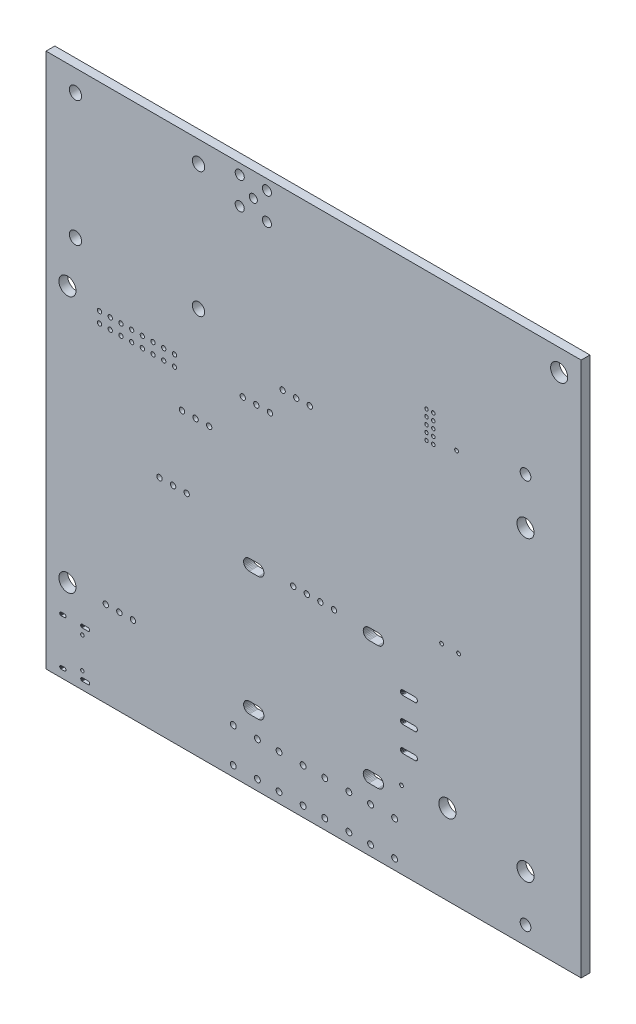
from build123d import *

# Parameters (mm, degrees)
SKICA1_W                = 100
SKICA1_H                = 100
SKICA1_R                = 1.15
SKICA1_R_2              = 0.85
SKICA1_R_3              = 0.75
SKICA1_R_4              = 1.6
SKICA1_R_5              = 0.4
SKICA1_R_6              = 0.5
SKICA1_R_7              = 0.325
SKICA1_R_8              = 1
SKICA1_R_9              = 0.35
SKICA1_R_10             = 0.55
P_IDAT_VYSUNUT_M1_DEPTH = 1.64716


with BuildPart() as part:
    # Skica1 → Přidat vysunutím1 (new body)
    with BuildSketch(Plane.XY.offset(1.64716)):
        with Locations((50, -50)):
            Rectangle(SKICA1_W, SKICA1_H)
        with Locations((5.5, -4)):
            Circle(SKICA1_R, mode=Mode.SUBTRACT)
        with Locations((28.5, -4)):
            Circle(SKICA1_R, mode=Mode.SUBTRACT)
        with Locations((36.195, -1.92)):
            Circle(SKICA1_R_2, mode=Mode.SUBTRACT)
        with Locations((36.195, -7)):
            Circle(SKICA1_R_2, mode=Mode.SUBTRACT)
        with Locations((41.275, -1.92)):
            Circle(SKICA1_R_2, mode=Mode.SUBTRACT)
        with Locations((38.735, -4.46)):
            Circle(SKICA1_R_3, mode=Mode.SUBTRACT)
        with Locations((41.275, -7)):
            Circle(SKICA1_R_2, mode=Mode.SUBTRACT)
        with Locations((5.5, -27.46)):
            Circle(SKICA1_R, mode=Mode.SUBTRACT)
        with Locations((4, -36)):
            Circle(SKICA1_R_4, mode=Mode.SUBTRACT)
        with Locations((10, -37.08)):
            Circle(SKICA1_R_5, mode=Mode.SUBTRACT)
        with Locations((12, -37.08)):
            Circle(SKICA1_R_5, mode=Mode.SUBTRACT)
        with Locations((14, -37.08)):
            Circle(SKICA1_R_5, mode=Mode.SUBTRACT)
        with Locations((16, -37.08)):
            Circle(SKICA1_R_5, mode=Mode.SUBTRACT)
        with Locations((18, -37.08)):
            Circle(SKICA1_R_5, mode=Mode.SUBTRACT)
        with Locations((20, -37.08)):
            Circle(SKICA1_R_5, mode=Mode.SUBTRACT)
        with Locations((22, -37.08)):
            Circle(SKICA1_R_5, mode=Mode.SUBTRACT)
        with Locations((24, -37.08)):
            Circle(SKICA1_R_5, mode=Mode.SUBTRACT)
        with Locations((10, -39.08)):
            Circle(SKICA1_R_5, mode=Mode.SUBTRACT)
        with Locations((12, -39.08)):
            Circle(SKICA1_R_5, mode=Mode.SUBTRACT)
        with Locations((14, -39.08)):
            Circle(SKICA1_R_5, mode=Mode.SUBTRACT)
        with Locations((16, -39.08)):
            Circle(SKICA1_R_5, mode=Mode.SUBTRACT)
        with Locations((18, -39.08)):
            Circle(SKICA1_R_5, mode=Mode.SUBTRACT)
        with Locations((20, -39.08)):
            Circle(SKICA1_R_5, mode=Mode.SUBTRACT)
        with Locations((22, -39.08)):
            Circle(SKICA1_R_5, mode=Mode.SUBTRACT)
        with Locations((24, -39.08)):
            Circle(SKICA1_R_5, mode=Mode.SUBTRACT)
        with Locations((25.415, -45.466)):
            Circle(SKICA1_R_6, mode=Mode.SUBTRACT)
        with Locations((28.5, -27.46)):
            Circle(SKICA1_R, mode=Mode.SUBTRACT)
        with Locations((36.766, -37.592)):
            Circle(SKICA1_R_6, mode=Mode.SUBTRACT)
        with Locations((39.306, -37.592)):
            Circle(SKICA1_R_6, mode=Mode.SUBTRACT)
        with Locations((41.846, -37.592)):
            Circle(SKICA1_R_6, mode=Mode.SUBTRACT)
        with Locations((44.211, -32.766)):
            Circle(SKICA1_R_6, mode=Mode.SUBTRACT)
        with Locations((46.751, -32.766)):
            Circle(SKICA1_R_6, mode=Mode.SUBTRACT)
        with Locations((49.291, -32.766)):
            Circle(SKICA1_R_6, mode=Mode.SUBTRACT)
        with Locations((27.955, -45.466)):
            Circle(SKICA1_R_6, mode=Mode.SUBTRACT)
        with Locations((30.495, -45.466)):
            Circle(SKICA1_R_6, mode=Mode.SUBTRACT)
        with Locations((71.1, -22.37)):
            Circle(SKICA1_R_7, mode=Mode.SUBTRACT)
        with Locations((72.37, -22.37)):
            Circle(SKICA1_R_7, mode=Mode.SUBTRACT)
        with Locations((71.1, -23.64)):
            Circle(SKICA1_R_7, mode=Mode.SUBTRACT)
        with Locations((72.37, -23.64)):
            Circle(SKICA1_R_7, mode=Mode.SUBTRACT)
        with Locations((71.1, -24.91)):
            Circle(SKICA1_R_7, mode=Mode.SUBTRACT)
        with Locations((72.37, -24.91)):
            Circle(SKICA1_R_7, mode=Mode.SUBTRACT)
        with Locations((95.885, -4.064)):
            Circle(SKICA1_R_4, mode=Mode.SUBTRACT)
        with Locations((89.6, -23.7)):
            Circle(SKICA1_R_8, mode=Mode.SUBTRACT)
        with Locations((71.1, -26.18)):
            Circle(SKICA1_R_7, mode=Mode.SUBTRACT)
        with Locations((72.37, -26.18)):
            Circle(SKICA1_R_7, mode=Mode.SUBTRACT)
        with Locations((71.1, -27.45)):
            Circle(SKICA1_R_7, mode=Mode.SUBTRACT)
        with Locations((72.37, -27.45)):
            Circle(SKICA1_R_7, mode=Mode.SUBTRACT)
        with Locations((76.708, -26.289)):
            Circle(SKICA1_R_9, mode=Mode.SUBTRACT)
        with Locations((89.6, -32.345)):
            Circle(SKICA1_R_4, mode=Mode.SUBTRACT)
        with Locations((21.209, -58.42)):
            Circle(SKICA1_R_6, mode=Mode.SUBTRACT)
        with Locations((23.749, -58.42)):
            Circle(SKICA1_R_6, mode=Mode.SUBTRACT)
        with Locations((26.289, -58.42)):
            Circle(SKICA1_R_6, mode=Mode.SUBTRACT)
        with Locations((46.19, -63.5)):
            Circle(SKICA1_R_6, mode=Mode.SUBTRACT)
        with Locations((48.73, -63.5)):
            Circle(SKICA1_R_6, mode=Mode.SUBTRACT)
        with Locations((4, -84)):
            Circle(SKICA1_R_4, mode=Mode.SUBTRACT)
        with Locations((11.161, -83.947)):
            Circle(SKICA1_R_6, mode=Mode.SUBTRACT)
        with Locations((13.701, -83.947)):
            Circle(SKICA1_R_6, mode=Mode.SUBTRACT)
        with Locations((16.241, -83.947)):
            Circle(SKICA1_R_6, mode=Mode.SUBTRACT)
        with Locations((6.791, -91.09)):
            Circle(SKICA1_R_7, mode=Mode.SUBTRACT)
        with Locations((6.791, -96.87)):
            Circle(SKICA1_R_7, mode=Mode.SUBTRACT)
        with Locations((34.992, -91.58)):
            Circle(SKICA1_R_10, mode=Mode.SUBTRACT)
        with Locations((34.992, -98.08)):
            Circle(SKICA1_R_10, mode=Mode.SUBTRACT)
        with Locations((39.492, -91.58)):
            Circle(SKICA1_R_10, mode=Mode.SUBTRACT)
        with Locations((43.542, -91.58)):
            Circle(SKICA1_R_10, mode=Mode.SUBTRACT)
        with Locations((48.042, -91.58)):
            Circle(SKICA1_R_10, mode=Mode.SUBTRACT)
        with Locations((39.492, -98.08)):
            Circle(SKICA1_R_10, mode=Mode.SUBTRACT)
        with Locations((43.542, -98.08)):
            Circle(SKICA1_R_10, mode=Mode.SUBTRACT)
        with Locations((48.042, -98.08)):
            Circle(SKICA1_R_10, mode=Mode.SUBTRACT)
        with Locations((51.27, -63.5)):
            Circle(SKICA1_R_6, mode=Mode.SUBTRACT)
        with Locations((53.81, -63.5)):
            Circle(SKICA1_R_6, mode=Mode.SUBTRACT)
        with Locations((73.914, -58.928)):
            Circle(SKICA1_R_9, mode=Mode.SUBTRACT)
        with Locations((77.089, -58.928)):
            Circle(SKICA1_R_9, mode=Mode.SUBTRACT)
        with Locations((66.421, -85.598)):
            Circle(SKICA1_R_9, mode=Mode.SUBTRACT)
        with Locations((52.092, -91.58)):
            Circle(SKICA1_R_10, mode=Mode.SUBTRACT)
        with Locations((56.592, -91.58)):
            Circle(SKICA1_R_10, mode=Mode.SUBTRACT)
        with Locations((60.642, -91.58)):
            Circle(SKICA1_R_10, mode=Mode.SUBTRACT)
        with Locations((52.092, -98.08)):
            Circle(SKICA1_R_10, mode=Mode.SUBTRACT)
        with Locations((56.592, -98.08)):
            Circle(SKICA1_R_10, mode=Mode.SUBTRACT)
        with Locations((60.642, -98.08)):
            Circle(SKICA1_R_10, mode=Mode.SUBTRACT)
        with Locations((65.142, -91.58)):
            Circle(SKICA1_R_10, mode=Mode.SUBTRACT)
        with Locations((65.142, -98.08)):
            Circle(SKICA1_R_10, mode=Mode.SUBTRACT)
        with Locations((75, -85)):
            Circle(SKICA1_R_4, mode=Mode.SUBTRACT)
        with Locations((89.6, -87.955)):
            Circle(SKICA1_R_4, mode=Mode.SUBTRACT)
        with Locations((89.6, -96.6)):
            Circle(SKICA1_R_8, mode=Mode.SUBTRACT)
        Polygon((40.257349, -63.261957), (40.416462, -63.392538), (40.547043, -63.551651), (40.644074, -63.733182), (40.703825, -63.930155), (40.724, -64.135), (40.703825, -64.339845), (40.644074, -64.536818), (40.547043, -64.718349), (40.416462, -64.877462), (40.257349, -65.008043), (40.075818, -65.105074), (39.878845, -65.164825), (39.674, -65.185), (37.974, -65.185), (37.769155, -65.164825), (37.572182, -65.105074), (37.390651, -65.008043), (37.231538, -64.877462), (37.100957, -64.718349), (37.003926, -64.536818), (36.944175, -64.339845), (36.924, -64.135), (36.944175, -63.930155), (37.003926, -63.733182), (37.100957, -63.551651), (37.231538, -63.392538), (37.390651, -63.261957), (37.572182, -63.164926), (37.769155, -63.105175), (37.974, -63.085), (39.674, -63.085), (39.878845, -63.105175), (40.075818, -63.164926), align=None, mode=Mode.SUBTRACT)
        Polygon((3.680405, -89.47921), (3.729548, -89.577901), (3.73972, -89.687681), (3.709549, -89.793722), (3.643109, -89.881703), (3.549372, -89.939742), (3.441, -89.96), (2.841, -89.96), (2.785875, -89.954892), (2.68307, -89.915065), (2.601595, -89.84079), (2.552452, -89.742099), (2.54228, -89.632319), (2.572451, -89.526278), (2.638891, -89.438297), (2.732628, -89.380258), (2.841, -89.36), (3.441, -89.36), (3.496125, -89.365108), (3.59893, -89.404935), align=None, mode=Mode.SUBTRACT)
        Polygon((8.110405, -89.47921), (8.159548, -89.577901), (8.16972, -89.687681), (8.139549, -89.793722), (8.073109, -89.881703), (7.979372, -89.939742), (7.871, -89.96), (6.771, -89.96), (6.715875, -89.954892), (6.61307, -89.915065), (6.531595, -89.84079), (6.482452, -89.742099), (6.47228, -89.632319), (6.502451, -89.526278), (6.568891, -89.438297), (6.662628, -89.380258), (6.771, -89.36), (7.871, -89.36), (7.926125, -89.365108), (8.02893, -89.404935), align=None, mode=Mode.SUBTRACT)
        Polygon((3.680405, -98.11921), (3.729548, -98.217901), (3.73972, -98.327681), (3.709549, -98.433722), (3.643109, -98.521703), (3.549372, -98.579742), (3.441, -98.6), (2.841, -98.6), (2.785875, -98.594892), (2.68307, -98.555065), (2.601595, -98.48079), (2.552452, -98.382099), (2.54228, -98.272319), (2.572451, -98.166278), (2.638891, -98.078297), (2.732628, -98.020258), (2.841, -98), (3.441, -98), (3.496125, -98.005108), (3.59893, -98.044935), align=None, mode=Mode.SUBTRACT)
        Polygon((8.110405, -98.11921), (8.159548, -98.217901), (8.16972, -98.327681), (8.139549, -98.433722), (8.073109, -98.521703), (7.979372, -98.579742), (7.871, -98.6), (6.771, -98.6), (6.715875, -98.594892), (6.61307, -98.555065), (6.531595, -98.48079), (6.482452, -98.382099), (6.47228, -98.272319), (6.502451, -98.166278), (6.568891, -98.078297), (6.662628, -98.020258), (6.771, -98), (7.871, -98), (7.926125, -98.005108), (8.02893, -98.044935), align=None, mode=Mode.SUBTRACT)
        Polygon((40.257349, -86.375957), (40.416462, -86.506538), (40.547043, -86.665651), (40.644074, -86.847182), (40.703825, -87.044155), (40.724, -87.249), (40.703825, -87.453845), (40.644074, -87.650818), (40.547043, -87.832349), (40.416462, -87.991462), (40.257349, -88.122043), (40.075818, -88.219074), (39.878845, -88.278825), (39.674, -88.299), (37.974, -88.299), (37.769155, -88.278825), (37.572182, -88.219074), (37.390651, -88.122043), (37.231538, -87.991462), (37.100957, -87.832349), (37.003926, -87.650818), (36.944175, -87.453845), (36.924, -87.249), (36.944175, -87.044155), (37.003926, -86.847182), (37.100957, -86.665651), (37.231538, -86.506538), (37.390651, -86.375957), (37.572182, -86.278926), (37.769155, -86.219175), (37.974, -86.199), (39.674, -86.199), (39.878845, -86.219175), (40.075818, -86.278926), align=None, mode=Mode.SUBTRACT)
        Polygon((62.609349, -63.261957), (62.768462, -63.392538), (62.899043, -63.551651), (62.996074, -63.733182), (63.055825, -63.930155), (63.076, -64.135), (63.055825, -64.339845), (62.996074, -64.536818), (62.899043, -64.718349), (62.768462, -64.877462), (62.609349, -65.008043), (62.427818, -65.105074), (62.230845, -65.164825), (62.026, -65.185), (60.326, -65.185), (60.121155, -65.164825), (59.924182, -65.105074), (59.742651, -65.008043), (59.583538, -64.877462), (59.452957, -64.718349), (59.355926, -64.536818), (59.296175, -64.339845), (59.276, -64.135), (59.296175, -63.930155), (59.355926, -63.733182), (59.452957, -63.551651), (59.583538, -63.392538), (59.742651, -63.261957), (59.924182, -63.164926), (60.121155, -63.105175), (60.326, -63.085), (62.026, -63.085), (62.230845, -63.105175), (62.427818, -63.164926), align=None, mode=Mode.SUBTRACT)
        Polygon((69.274078, -70.155127), (69.357711, -70.26), (69.406718, -70.384866), (69.416742, -70.518629), (69.386893, -70.649403), (69.319824, -70.76557), (69.221494, -70.856807), (69.10064, -70.915008), (68.968, -70.935), (66.668, -70.935), (66.600931, -70.929974), (66.472752, -70.890436), (66.361922, -70.814873), (66.278289, -70.71), (66.229282, -70.585134), (66.219258, -70.451371), (66.249107, -70.320597), (66.316176, -70.20443), (66.414506, -70.113193), (66.53536, -70.054992), (66.668, -70.035), (68.968, -70.035), (69.035069, -70.040026), (69.163248, -70.079564), align=None, mode=Mode.SUBTRACT)
        Polygon((69.274078, -74.854127), (69.357711, -74.959), (69.406718, -75.083866), (69.416742, -75.217629), (69.386893, -75.348403), (69.319824, -75.46457), (69.221494, -75.555807), (69.10064, -75.614008), (68.968, -75.634), (66.668, -75.634), (66.600931, -75.628974), (66.472752, -75.589436), (66.361922, -75.513873), (66.278289, -75.409), (66.229282, -75.284134), (66.219258, -75.150371), (66.249107, -75.019597), (66.316176, -74.90343), (66.414506, -74.812193), (66.53536, -74.753992), (66.668, -74.734), (68.968, -74.734), (69.035069, -74.739026), (69.163248, -74.778564), align=None, mode=Mode.SUBTRACT)
        Polygon((69.274078, -79.553127), (69.357711, -79.658), (69.406718, -79.782866), (69.416742, -79.916629), (69.386893, -80.047403), (69.319824, -80.16357), (69.221494, -80.254807), (69.10064, -80.313008), (68.968, -80.333), (66.668, -80.333), (66.600931, -80.327974), (66.472752, -80.288436), (66.361922, -80.212873), (66.278289, -80.108), (66.229282, -79.983134), (66.219258, -79.849371), (66.249107, -79.718597), (66.316176, -79.60243), (66.414506, -79.511193), (66.53536, -79.452992), (66.668, -79.433), (68.968, -79.433), (69.035069, -79.438026), (69.163248, -79.477564), align=None, mode=Mode.SUBTRACT)
        Polygon((62.609349, -86.375957), (62.768462, -86.506538), (62.899043, -86.665651), (62.996074, -86.847182), (63.055825, -87.044155), (63.076, -87.249), (63.055825, -87.453845), (62.996074, -87.650818), (62.899043, -87.832349), (62.768462, -87.991462), (62.609349, -88.122043), (62.427818, -88.219074), (62.230845, -88.278825), (62.026, -88.299), (60.326, -88.299), (60.121155, -88.278825), (59.924182, -88.219074), (59.742651, -88.122043), (59.583538, -87.991462), (59.452957, -87.832349), (59.355926, -87.650818), (59.296175, -87.453845), (59.276, -87.249), (59.296175, -87.044155), (59.355926, -86.847182), (59.452957, -86.665651), (59.583538, -86.506538), (59.742651, -86.375957), (59.924182, -86.278926), (60.121155, -86.219175), (60.326, -86.199), (62.026, -86.199), (62.230845, -86.219175), (62.427818, -86.278926), align=None, mode=Mode.SUBTRACT)
    extrude(amount=-P_IDAT_VYSUNUT_M1_DEPTH)


solid = part.part
